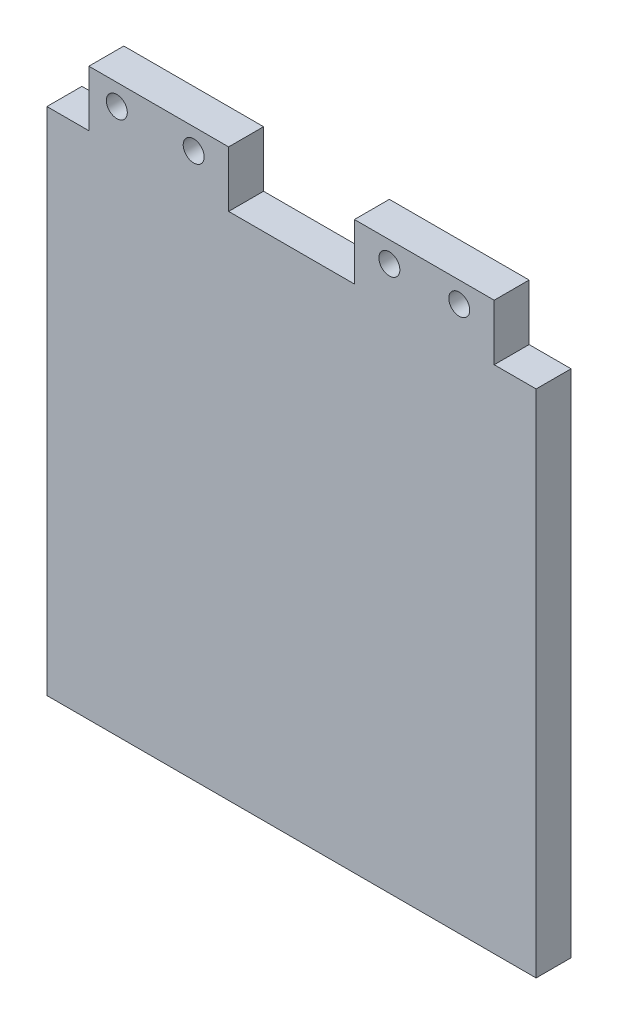
from build123d import *

# Parameters (mm, degrees)
RESSALTO_EXTRUS_O1_DEPTH = 5
ESBO_O2_R                = 1.5
CORTE_EXTRUS_O1_DEPTH    = 10
ESBO_O3_R                = 1.5
CORTE_EXTRUS_O2_DEPTH    = 6


with BuildPart() as part:
    # Esboço1 → Ressalto-extrusão1 (new body)
    with BuildSketch(Plane.XY):
        Polygon((-1.556986729, 38.142857143), (16.443013271, 38.142857143), (16.443013271, 46.142857143), (36.443013271, 46.142857143), (36.443013271, 38.142857143), (42.443013271, 38.142857143), (42.443013271, -34.857142857), (-27.556986729, -34.857142857), (-27.556986729, 38.142857143), (-21.556986729, 38.142857143), (-21.556986729, 46.142857143), (-1.556986729, 46.142857143), align=None)
    extrude(amount=RESSALTO_EXTRUS_O1_DEPTH)

    # Esboço2 → Corte-extrusão1 (cut)
    with BuildSketch(Plane.XY.offset(5)):
        with Locations((-17.556986729, 43.142857143)):
            Circle(ESBO_O2_R)
        with Locations((-6.556986729, 43.142857143)):
            Circle(ESBO_O2_R)
    extrude(amount=-CORTE_EXTRUS_O1_DEPTH, mode=Mode.SUBTRACT)

    # Esboço3 → Corte-extrusão2 (cut, through all)
    with BuildSketch(Plane.XY.offset(5)):
        with Locations((21.443013271, 43.142857143)):
            Circle(ESBO_O3_R)
        with Locations((31.443013271, 43.142857143)):
            Circle(ESBO_O3_R)
    extrude(amount=-CORTE_EXTRUS_O2_DEPTH, mode=Mode.SUBTRACT)


solid = part.part
